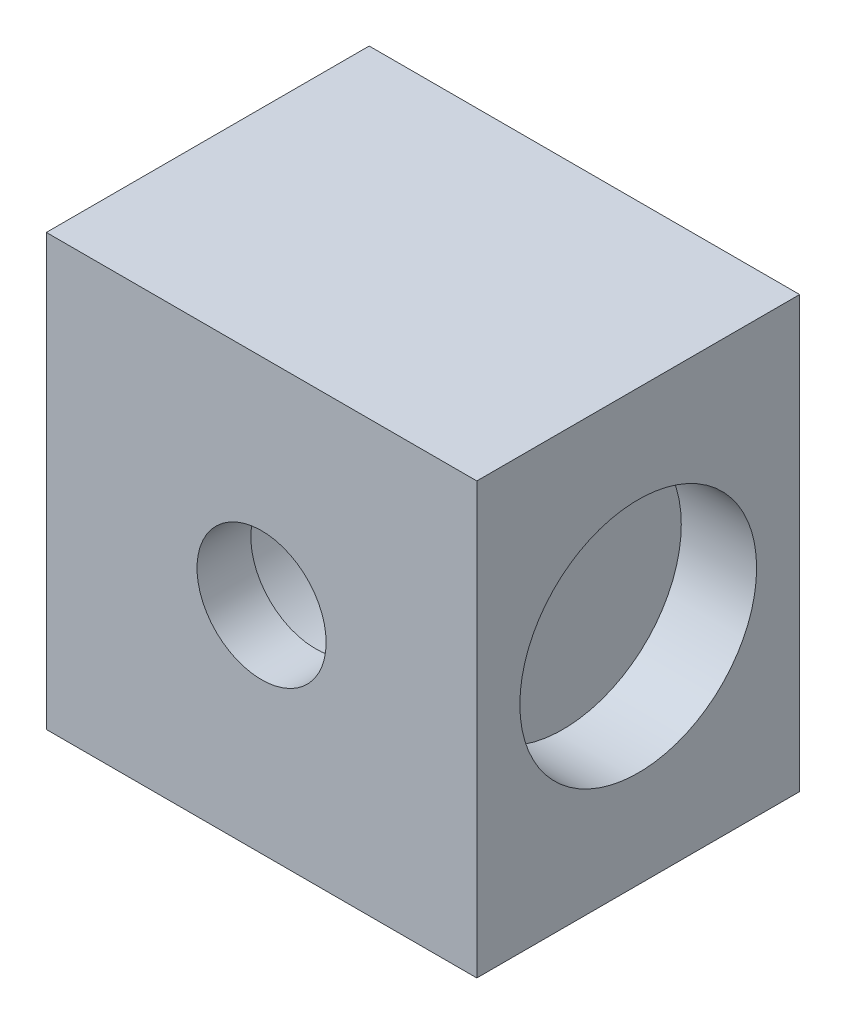
from build123d import *

# Parameters (mm, degrees)
SKETCH2_W           = 40
SKETCH2_H           = 40
BOSS_EXTRUDE1_DEPTH = 30
SKETCH6_W           = 26
SKETCH6_H           = 26
BOSS_EXTRUDE2_DEPTH = 40
SKETCH7_R           = 11
CUT_EXTRUDE3_DEPTH  = 7
SKETCH3_R           = 6
CUT_EXTRUDE4_DEPTH  = 5
SKETCH4_R           = 10
CUT_EXTRUDE5_DEPTH  = 25


with BuildPart() as part:
    # Sketch2 → Boss-Extrude1 (new body)
    with BuildSketch(Plane.XY):
        Rectangle(SKETCH2_W, SKETCH2_H)
    extrude(amount=BOSS_EXTRUDE1_DEPTH)

    # Sketch6 → Boss-Extrude2 (add)
    with BuildSketch(Plane(origin=(20, 0, 0), x_dir=(0, 0, -1), z_dir=(1, 0, 0))):
        with Locations((-15, 0)):
            Rectangle(SKETCH6_W, SKETCH6_H)
    extrude(amount=-BOSS_EXTRUDE2_DEPTH)

    # Sketch7 → Cut-Extrude3 (cut)
    with BuildSketch(Plane(origin=(20, 0, 0), x_dir=(0, 0, -1), z_dir=(1, 0, 0))):
        with Locations((-15, 0)):
            Circle(SKETCH7_R)
    extrude(amount=-CUT_EXTRUDE3_DEPTH, mode=Mode.SUBTRACT)

    # Sketch3 → Cut-Extrude4 (cut)
    with BuildSketch(Plane.XY.offset(30)):
        Circle(SKETCH3_R)
    extrude(amount=-CUT_EXTRUDE4_DEPTH, mode=Mode.SUBTRACT)

    # Sketch4 → Cut-Extrude5 (cut)
    with BuildSketch(Plane(origin=(0, 0, 0), x_dir=(-1, 0, 0), z_dir=(0, 0, -1))):
        Circle(SKETCH4_R)
    extrude(amount=-CUT_EXTRUDE5_DEPTH, mode=Mode.SUBTRACT)


solid = part.part
